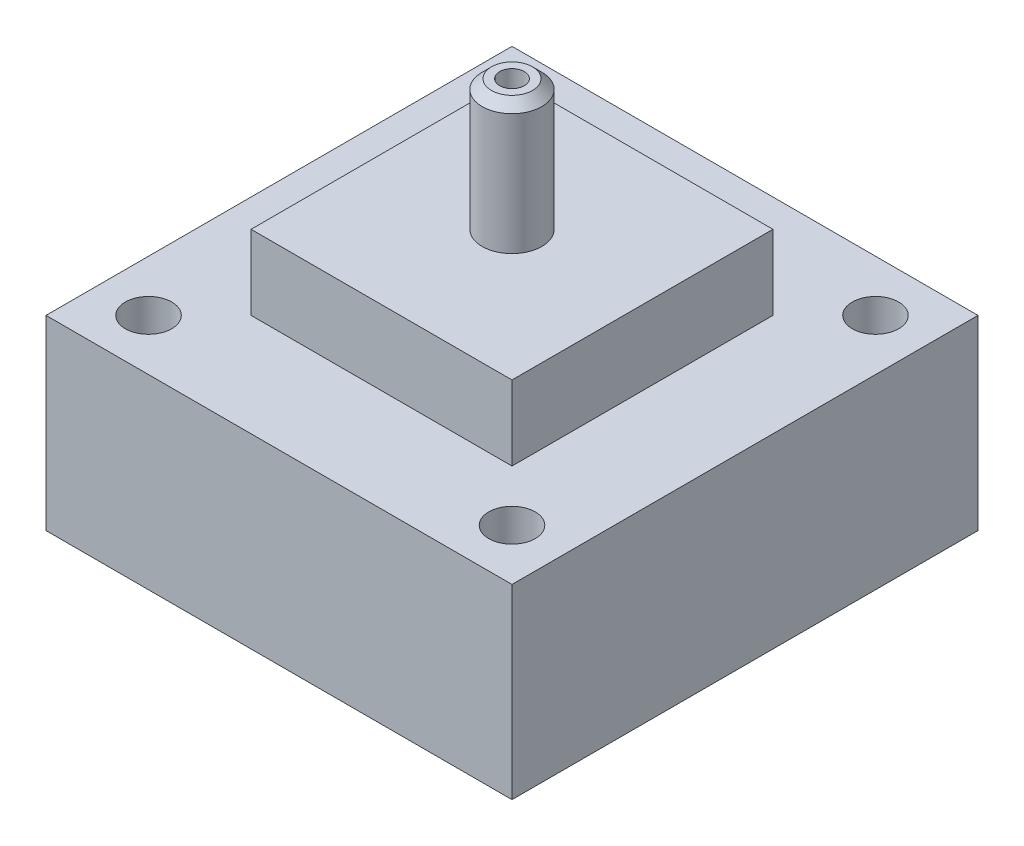
from build123d import *

# Parameters (mm, degrees)
SKETCH1_W           = 14
SKETCH1_H           = 14
BOSS_EXTRUDE1_DEPTH = 4
SKETCH2_W           = 25
SKETCH2_H           = 25
SKETCH2_R           = 1.2446
BOSS_EXTRUDE2_DEPTH = 10
SKETCH3_R           = 4.23
CUT_EXTRUDE1_DEPTH  = 9.8
SKETCH5_R           = 0.6604
CUT_EXTRUDE2_DEPTH  = 14


with BuildPart() as part:
    # Sketch1 → Boss-Extrude1 (new body)
    with BuildSketch(Plane(origin=(0, 0, 0), x_dir=(1, 0, 0), z_dir=(0, 1, 0))):
        Rectangle(SKETCH1_W, SKETCH1_H)
    extrude(amount=BOSS_EXTRUDE1_DEPTH)

    # Sketch2 → Boss-Extrude2 (add)
    with BuildSketch(Plane.XZ):
        Rectangle(SKETCH2_W, SKETCH2_H)
        with Locations((-9.75, 9.75)):
            Circle(SKETCH2_R, mode=Mode.SUBTRACT)
        with Locations((9.75, 9.75)):
            Circle(SKETCH2_R, mode=Mode.SUBTRACT)
        with Locations((9.75, -9.75)):
            Circle(SKETCH2_R, mode=Mode.SUBTRACT)
        with Locations((-9.75, -9.75)):
            Circle(SKETCH2_R, mode=Mode.SUBTRACT)
    extrude(amount=BOSS_EXTRUDE2_DEPTH)

    # Sketch3 → Cut-Extrude1 (cut)
    with BuildSketch(Plane.XZ.offset(10)):
        Circle(SKETCH3_R)
    extrude(amount=-CUT_EXTRUDE1_DEPTH, mode=Mode.SUBTRACT)

    # Sketch4 → Revolve1 (revolve)
    with BuildSketch(Plane(origin=(0, 0, 0), x_dir=(0, 0, -1), z_dir=(1, 0, 0))):
        Polygon((0.6604, 11), (0.6604, 4), (1.6, 4), (1.6, 10.5), (1.1, 11), align=None)
    revolve(axis=Axis((0, 4, 0), (0, 1, 0)))

    # Sketch5 → Cut-Extrude2 (cut)
    with BuildSketch(Plane(origin=(0, 4, 0), x_dir=(1, 0, 0), z_dir=(0, 1, 0))):
        Circle(SKETCH5_R)
    extrude(amount=-CUT_EXTRUDE2_DEPTH, mode=Mode.SUBTRACT)


solid = part.part
